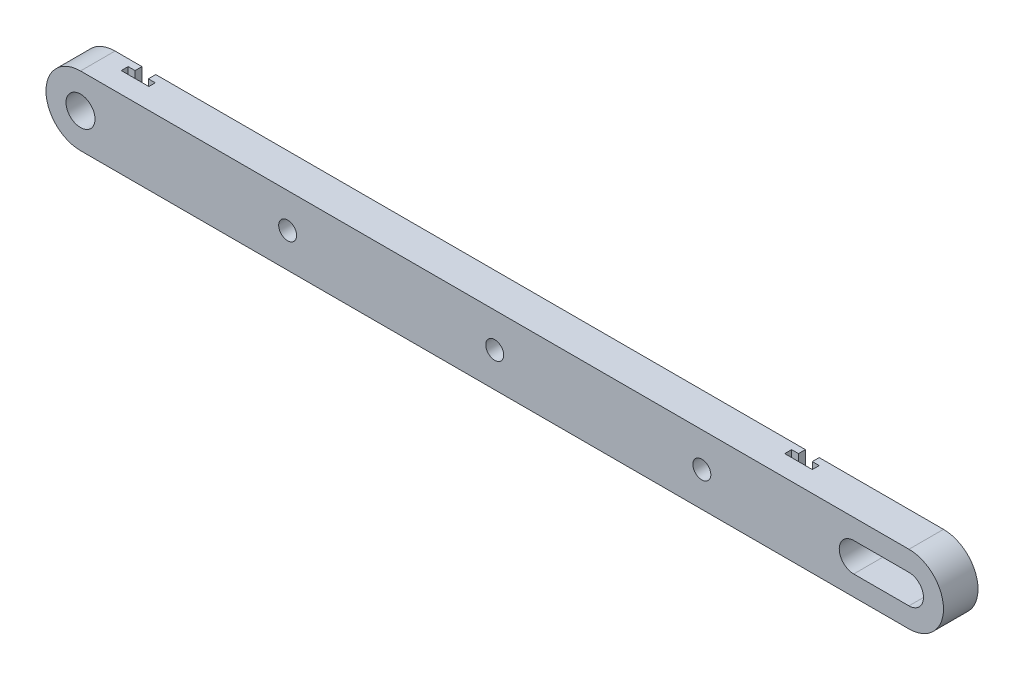
from build123d import *

# Parameters (mm, degrees)
ESQUISSE1_R             = 10.5
BOSS_EXTRU_1_DEPTH      = 25
ENL_V_MAT_EXTRU_1_DEPTH = 35
ENL_V_MAT_EXTRU_2_DEPTH = 50
ENL_V_MAT_EXTRU_3_DEPTH = 15
ESQUISSE1_4_R           = 6.5
ENL_V_MAT_EXTRU_4_DEPTH = 626.999201277
ESQUISSE1_5_R           = 10
ENL_V_MAT_EXTRU_5_DEPTH = 12


with BuildPart() as part:
    # Esquisse1 → Boss.-Extru.1 (new body)
    with BuildSketch(Plane.XY):
        with BuildLine():
            Line((600, -25), (0, -25))
            ThreePointArc((0, -25), (-25, 0), (0, 25))
            Line((0, 25), (600, 25))
            ThreePointArc((600, 25), (625, 0), (600, -25))
        make_face()
        Circle(ESQUISSE1_R, mode=Mode.SUBTRACT)
        with BuildLine():
            Line((560, 10.5), (600, 10.5))
            ThreePointArc((600, 10.5), (610.5, 0), (600, -10.5))
            Line((600, -10.5), (560, -10.5))
            ThreePointArc((560, -10.5), (549.5, 0), (560, 10.5))
        make_face(mode=Mode.SUBTRACT)
    extrude(amount=BOSS_EXTRU_1_DEPTH)

    # Esquisse2 → Enl_v. mat.-Extru.1 (cut)
    with BuildSketch(Plane(origin=(0, 25, 0), x_dir=(1, 0, 0), z_dir=(0, 1, 0))):
        Polygon((510, 0), (500, 0), (500, -5), (495, -5), (495, -10), (515, -10), (515, -5), (510, -5), align=None)
    extrude(amount=-ENL_V_MAT_EXTRU_1_DEPTH, mode=Mode.SUBTRACT)

    # Esquisse3 → Enl_v. mat.-Extru.2 (cut)
    with BuildSketch(Plane(origin=(0, 25, 0), x_dir=(1, 0, 0), z_dir=(0, 1, 0))):
        Polygon((19.49708464, 0), (19.49708464, -5), (14.49708464, -5), (14.49708464, -10), (34.49708464, -10), (34.49708464, -5.357949986), (29.49708464, -5.357949986), (29.49708464, 0), align=None)
    extrude(amount=-ENL_V_MAT_EXTRU_2_DEPTH, mode=Mode.SUBTRACT)

    # Esquisse1_3 → Enl_v. mat.-Extru.3 (cut)
    with BuildSketch(Plane.XY):
        Polygon((545, -25), (555, -25), (555, -15), (537.5, -15), (537.5, -20), (545, -20), align=None)
        Polygon((290, -25), (310, -25), (310, -20), (317.5, -20), (317.5, -15), (282.5, -15), (282.5, -20), (290, -20), align=None)
        Polygon((45, -15), (45, -25), (55, -25), (55, -20), (62.5, -20), (62.5, -15), align=None)
    extrude(amount=ENL_V_MAT_EXTRU_3_DEPTH, mode=Mode.SUBTRACT)

    # Esquisse1_4 → Enl_v. mat.-Extru.4 (cut, through all)
    with BuildSketch(Plane.XY):
        with Locations((300, 0)):
            Circle(ESQUISSE1_4_R)
        with Locations((450, 0)):
            Circle(ESQUISSE1_4_R)
        with Locations((150, 0)):
            Circle(ESQUISSE1_4_R)
    extrude(amount=ENL_V_MAT_EXTRU_4_DEPTH, mode=Mode.SUBTRACT)

    # Esquisse1_5 → Enl_v. mat.-Extru.5 (cut)
    with BuildSketch(Plane.XY):
        with Locations((300, 0)):
            Circle(ESQUISSE1_5_R)
        with Locations((450, 0)):
            Circle(ESQUISSE1_5_R)
        with Locations((150, 0)):
            Circle(ESQUISSE1_5_R)
    extrude(amount=ENL_V_MAT_EXTRU_5_DEPTH, mode=Mode.SUBTRACT)


solid = part.part
